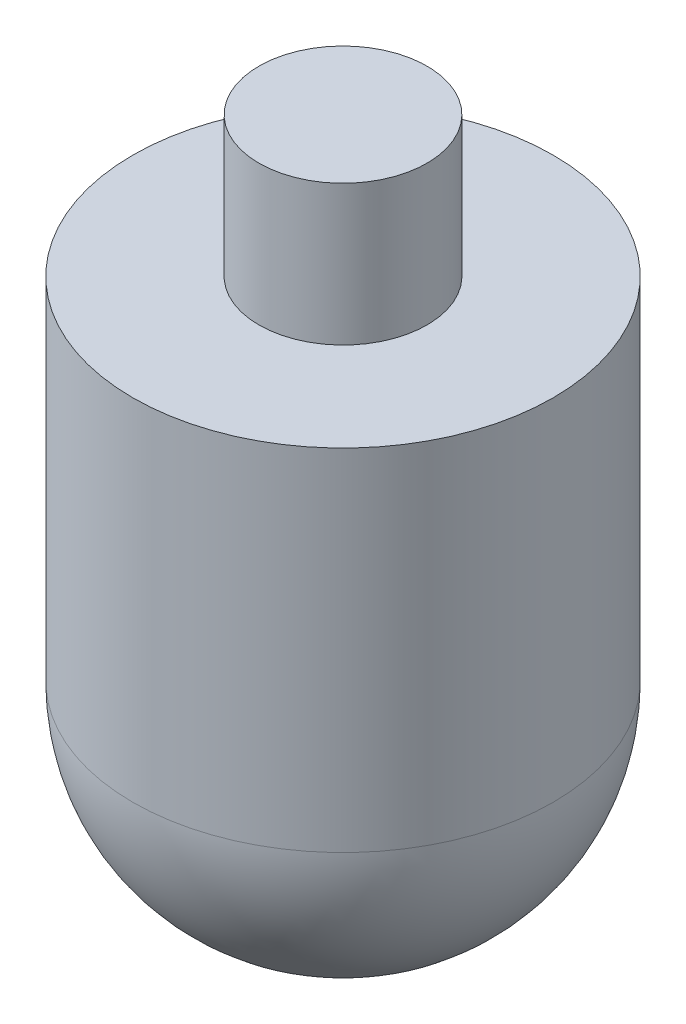
from build123d import *


with BuildPart() as part:
    # Sketch1 → Revolve1 (revolve)
    with BuildSketch(Plane.XY, mode=Mode.PRIVATE) as revolve1_sk:
        with BuildLine():
            Line((0, 0), (6, 0))
            Line((6, 0), (6, -10))
            Line((6, -10), (15, -10))
            Line((15, -10), (15, -35))
            ThreePointArc((15, -35), (10.606601718, -45.606601718), (0, -50))
            Line((0, -50), (0, 0))
        make_face()
    revolve(revolve1_sk.sketch.rotate(Axis((0, 10.75, 0), (0, -1, 0)), 90), axis=Axis((0, 10.75, 0), (0, -1, 0)))  # turned: the seam where the file's is


solid = part.part
